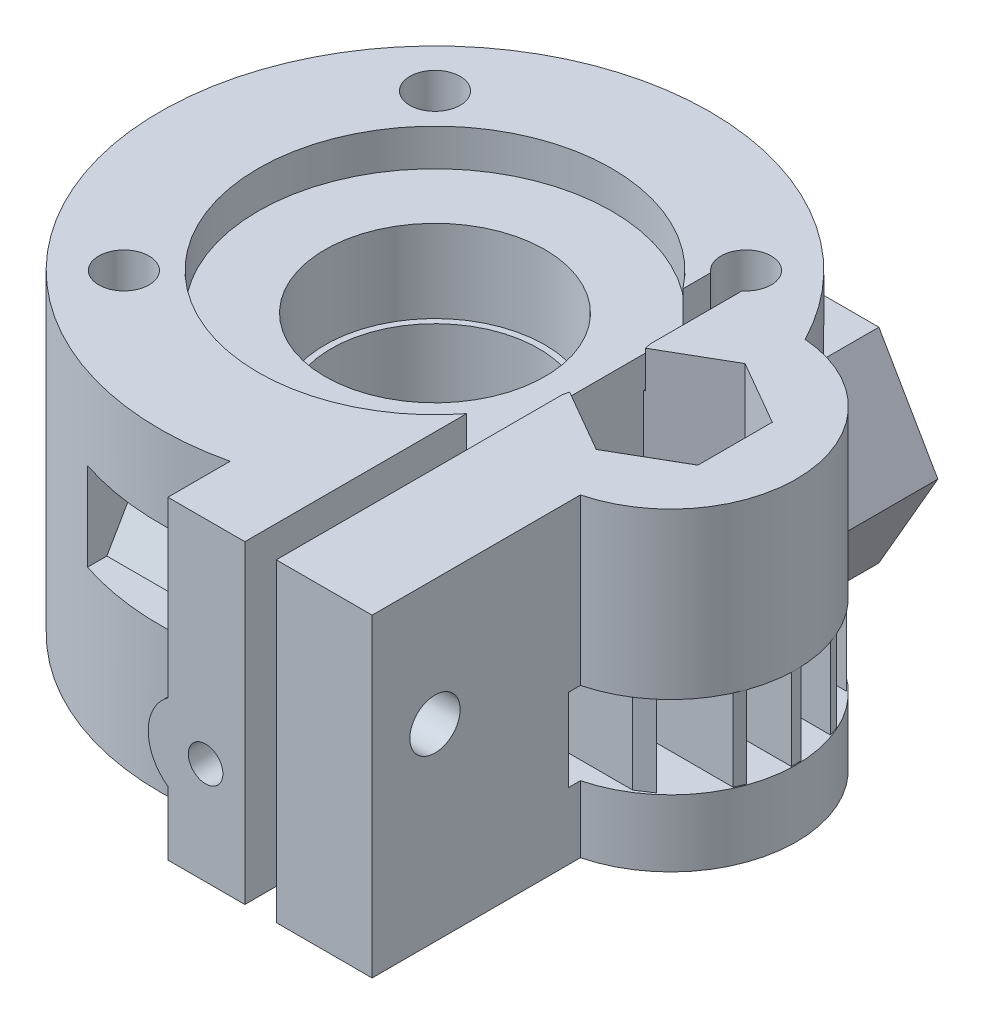
from build123d import *

# Parameters (mm, degrees)
BOSS_EXTRUDE1_DEPTH     = 20
CUT_EXTRUDE1_REACH      = 22
SKETCH2_R               = 6.6
SKETCH2_R_2             = 1.6
SKETCH2_R_3             = 2.6
SKETCH3_R               = 11.25
CUT_EXTRUDE2_DEPTH      = 2.35
SKETCH4_R               = 7
CUT_EXTRUDE3_DEPTH      = 5.25
CUT_EXTRUDE4_DEPTH      = 6
CUT_EXTRUDE5_DEPTH      = 5.25
BOSS_EXTRUDE2_REACH     = 40.5
SKETCH10_R              = 3
BOSS_EXTRUDE3_REACH     = 41
SKETCH8_R               = 1.1
CUT_EXTRUDE6_DEPTH      = 40
SKETCH14_R              = 2.25
CUT_EXTRUDE7_DEPTH      = 5
SKETCH15_R              = 1.6
CUT_EXTRUDE8_DEPTH      = 13
CUT_EXTRUDE9_DEPTH      = 9.5
CUT_EXTRUDE9_DEPTH_BACK = 1.5
BOSS_EXTRUDE4_REACH     = 17.75
SKETCH17_W              = 1.481378883
SKETCH17_H              = 0.6
SKETCH17_W_2            = 5.287146776
SKETCH17_W_3            = 2.276797121


with BuildPart() as part:
    # Sketch1 → Boss-Extrude1 (new body)
    with BuildSketch(Plane(origin=(0, 0, 0), x_dir=(1, 0, 0), z_dir=(0, 1, 0))):
        with BuildLine():
            Line((4, -21), (17, -21))
            Line((17, -21), (17, -7.745966692))
            ThreePointArc((17, -7.745966692), (22.967354114, 0.721989217), (15.575, 7.979309181))
            ThreePointArc((15.575, 7.979309181), (-15.882243174, 7.348765322), (4, -17.036725037))
            Line((4, -17.036725037), (4, -21))
        make_face()
    extrude(amount=BOSS_EXTRUDE1_DEPTH)

    # Sketch2 → Cut-Extrude1 (cut, up to next)
    with BuildSketch(Plane(origin=(0, 20, 0), x_dir=(1, 0, 0), z_dir=(0, 1, 0)), mode=Mode.PRIVATE) as cut_extrude1_sk1:
        Circle(SKETCH2_R)
    cut_extrude1_tool1 = extrude(cut_extrude1_sk1.sketch, amount=-CUT_EXTRUDE1_REACH, mode=Mode.PRIVATE) & part.part
    add(cut_extrude1_tool1.solids().sort_by_distance((0, 20, 0))[0], mode=Mode.SUBTRACT)
    # Sketch2 → Cut-Extrude1 (cut, up to next)
    with BuildSketch(Plane(origin=(0, 20, 0), x_dir=(1, 0, 0), z_dir=(0, 1, 0)), mode=Mode.PRIVATE) as cut_extrude1_sk2:
        with Locations((-9.899494937, 9.899494937)):
            Circle(SKETCH2_R_2)
    cut_extrude1_tool2 = extrude(cut_extrude1_sk2.sketch, amount=-CUT_EXTRUDE1_REACH, mode=Mode.PRIVATE) & part.part
    add(cut_extrude1_tool2.solids().sort_by_distance((-9.899495, 20, -9.899495))[0], mode=Mode.SUBTRACT)
    # Sketch2 → Cut-Extrude1 (cut, up to next)
    with BuildSketch(Plane(origin=(0, 20, 0), x_dir=(1, 0, 0), z_dir=(0, 1, 0)), mode=Mode.PRIVATE) as cut_extrude1_sk3:
        with Locations((-9.899494937, -9.899494937)):
            Circle(SKETCH2_R_2)
    cut_extrude1_tool3 = extrude(cut_extrude1_sk3.sketch, amount=-CUT_EXTRUDE1_REACH, mode=Mode.PRIVATE) & part.part
    add(cut_extrude1_tool3.solids().sort_by_distance((-9.899495, 20, 9.899495))[0], mode=Mode.SUBTRACT)
    # Sketch2 → Cut-Extrude1 (cut, up to next)
    with BuildSketch(Plane(origin=(0, 20, 0), x_dir=(1, 0, 0), z_dir=(0, 1, 0)), mode=Mode.PRIVATE) as cut_extrude1_sk4:
        with Locations((15, 0)):
            Circle(SKETCH2_R_3)
    cut_extrude1_tool4 = extrude(cut_extrude1_sk4.sketch, amount=-CUT_EXTRUDE1_REACH, mode=Mode.PRIVATE) & part.part
    add(cut_extrude1_tool4.solids().sort_by_distance((15, 20, 0))[0], mode=Mode.SUBTRACT)
    # Sketch2 → Cut-Extrude1 (cut, up to next)
    with BuildSketch(Plane(origin=(0, 20, 0), x_dir=(1, 0, 0), z_dir=(0, 1, 0)), mode=Mode.PRIVATE) as cut_extrude1_sk5:
        with BuildLine():
            Line((8.899494937, -21), (8.899494937, 8.650495337))
            ThreePointArc((8.899494937, 8.650495337), (9.899494937, 11.499494937), (10.899494937, 8.650495337))
            Line((10.899494937, 8.650495337), (10.899494937, -21))
            Line((10.899494937, -21), (8.899494937, -21))
        make_face()
    cut_extrude1_tool5 = extrude(cut_extrude1_sk5.sketch, amount=-CUT_EXTRUDE1_REACH, mode=Mode.PRIVATE) & part.part
    add(cut_extrude1_tool5.solids().sort_by_distance((9.899495, 20, 4.346591))[0], mode=Mode.SUBTRACT)

    # Sketch3 → Cut-Extrude2 (cut)
    with BuildSketch(Plane(origin=(0, 20, 0), x_dir=(1, 0, 0), z_dir=(0, 1, 0))):
        Circle(SKETCH3_R)
    extrude(amount=-CUT_EXTRUDE2_DEPTH, mode=Mode.SUBTRACT)

    # Sketch4 → Cut-Extrude3 (cut)
    with BuildSketch(Plane(origin=(0, 17.65, 0), x_dir=(1, 0, 0), z_dir=(0, 1, 0))):
        Circle(SKETCH4_R)
    extrude(amount=-CUT_EXTRUDE3_DEPTH, mode=Mode.SUBTRACT)

    # Sketch5 → Cut-Extrude4 (cut)
    with BuildSketch(Plane(origin=(0, 20, 0), x_dir=(1, 0, 0), z_dir=(0, 1, 0))):
        Polygon((19.100505063, 2.367427702), (15, 4.734855404), (10.899494937, 2.367427702), (10.899494937, -2.367427702), (15, -4.734855404), (19.100505063, -2.367427702), align=None)
    extrude(amount=-CUT_EXTRUDE4_DEPTH, mode=Mode.SUBTRACT)

    # Sketch6 → Cut-Extrude5 (cut)
    with BuildSketch(Plane(origin=(0, 4.25, 0), x_dir=(1, 0, 0), z_dir=(0, 1, 0))):
        with BuildLine():
            Line((15, 8.5), (23.5, 8.5))
            Line((23.5, 8.5), (23.5, 0))
            Line((23.5, 0), (23.5, -8.5))
            Line((23.5, -8.5), (15, -8.5))
            ThreePointArc((15, -8.5), (10.626786079, -7.288689869), (7.5, -4))
            Line((7.5, -4), (5, -4))
            Line((5, -4), (5, 0))
            Line((5, 0), (5, 4))
            Line((5, 4), (7.5, 4))
            ThreePointArc((7.5, 4), (10.626786079, 7.288689869), (15, 8.5))
        make_face()
    extrude(amount=CUT_EXTRUDE5_DEPTH, mode=Mode.SUBTRACT)

    # Sketch10 → Boss-Extrude2 (add, up to next)
    with BuildSketch(Plane.XY.offset(21), mode=Mode.PRIVATE) as boss_extrude2_sk1:
        with Locations((5.75, 6.5)):
            Circle(SKETCH10_R)
    boss_extrude2_tool1 = extrude(boss_extrude2_sk1.sketch, amount=-BOSS_EXTRUDE2_REACH, mode=Mode.PRIVATE) - part.part
    add(boss_extrude2_tool1.solids().sort_by_distance((5.75, 6.5, 21))[0])

    # Sketch11 → Boss-Extrude3 (add, up to next)
    with BuildSketch(Plane.XY.offset(-18), mode=Mode.PRIVATE) as boss_extrude3_sk1:
        Polygon((-1.005553499, 6.5), (2.74722325, 0), (10.25277675, 0), (14.005553499, 6.5), (10.25277675, 13), (2.74722325, 13), align=None)
    boss_extrude3_tool1 = extrude(boss_extrude3_sk1.sketch, amount=BOSS_EXTRUDE3_REACH, mode=Mode.PRIVATE) - part.part
    add(boss_extrude3_tool1.solids().sort_by_distance((6.5, 6.5, -18))[0])

    # Sketch8 → Cut-Extrude6 (cut, through all)
    with BuildSketch(Plane.XY.offset(21)):
        with Locations((6.399494937, 6.5)):
            Circle(SKETCH8_R)
    extrude(amount=-CUT_EXTRUDE6_DEPTH, mode=Mode.SUBTRACT)

    # Sketch13 → Cut-Revolve1 (revolve, cut)
    with BuildSketch(Plane.ZY.offset(-6.5)):
        Polygon((-6, 6.5), (-4, 6.5), (-4, 8.678199262), (-6, 7), align=None)
    revolve(axis=Axis((6.5, 6.5, -18), (0, 0, 1)), mode=Mode.SUBTRACT)

    # Sketch14 → Cut-Extrude7 (cut)
    with BuildSketch(Plane(origin=(0, 0, -18), x_dir=(-1, 0, 0), z_dir=(0, 0, -1))):
        with Locations((-6.399494937, 6.5)):
            Circle(SKETCH14_R)
    extrude(amount=-CUT_EXTRUDE7_DEPTH, mode=Mode.SUBTRACT)

    # Sketch15 → Cut-Extrude8 (cut)
    with BuildSketch(Plane(origin=(17, 0, 0), x_dir=(0, 0, -1), z_dir=(1, 0, 0))):
        with Locations((-17, 12)):
            Circle(SKETCH15_R)
    extrude(amount=-CUT_EXTRUDE8_DEPTH, mode=Mode.SUBTRACT)

    # Sketch16 → Cut-Extrude9 (cut, two sides)
    with BuildSketch(Plane.ZY.offset(-4)) as cut_extrude9_sk:
        Polygon((20.233161507, 12), (18.616580754, 14.8), (15.383419246, 14.8), (13.766838493, 12), (15.383419246, 9.2), (18.616580754, 9.2), align=None)
    extrude(amount=CUT_EXTRUDE9_DEPTH, mode=Mode.SUBTRACT)
    extrude(cut_extrude9_sk.sketch, amount=-CUT_EXTRUDE9_DEPTH_BACK, mode=Mode.SUBTRACT)

    # Sketch17 → Boss-Extrude4 (add, up to next)
    with BuildSketch(Plane(origin=(0, 4.25, 0), x_dir=(1, 0, 0), z_dir=(0, 1, 0)), mode=Mode.PRIVATE) as boss_extrude4_sk1:
        with Locations((11.640184379, 0.05)):
            Rectangle(SKETCH17_W, SKETCH17_H)
    boss_extrude4_tool1 = extrude(boss_extrude4_sk1.sketch, amount=BOSS_EXTRUDE4_REACH, mode=Mode.PRIVATE) - part.part
    add(boss_extrude4_tool1.solids().sort_by_distance((11.640184, 4.25, -0.05))[0])
    # Sketch17 → Boss-Extrude4 (add, up to next)
    with BuildSketch(Plane(origin=(0, 4.25, 0), x_dir=(1, 0, 0), z_dir=(0, 1, 0)), mode=Mode.PRIVATE) as boss_extrude4_sk2:
        Polygon((22.23765915, 3.330781542), (10.899494937, 3.330781542), (10.899494937, 2.730781542), (22.440052992, 2.730781542), align=None)
    boss_extrude4_tool2 = extrude(boss_extrude4_sk2.sketch, amount=BOSS_EXTRUDE4_REACH, mode=Mode.PRIVATE) - part.part
    add(boss_extrude4_tool2.solids().sort_by_distance((16.619325, 4.25, -3.029897))[0])
    # Sketch17 → Boss-Extrude4 (add, up to next)
    with BuildSketch(Plane(origin=(0, 4.25, 0), x_dir=(1, 0, 0), z_dir=(0, 1, 0)), mode=Mode.PRIVATE) as boss_extrude4_sk3:
        Polygon((22.477954877, -2.64697567), (10.899494937, -2.64697567), (10.899494937, -3.24697567), (22.217055012, -3.24697567), align=None)
    boss_extrude4_tool3 = extrude(boss_extrude4_sk3.sketch, amount=BOSS_EXTRUDE4_REACH, mode=Mode.PRIVATE) - part.part
    add(boss_extrude4_tool3.solids().sort_by_distance((16.623748, 4.25, 2.945836))[0])
    # Sketch17 → Boss-Extrude4 (add, up to next)
    with BuildSketch(Plane(origin=(0, 4.25, 0), x_dir=(1, 0, 0), z_dir=(0, 1, 0)), mode=Mode.PRIVATE) as boss_extrude4_sk4:
        Polygon((20.100469452, -6), (10.899494937, -6), (10.899494937, -6.6), (19.187050839, -6.6), align=None)
    boss_extrude4_tool4 = extrude(boss_extrude4_sk4.sketch, amount=BOSS_EXTRUDE4_REACH, mode=Mode.PRIVATE) - part.part
    add(boss_extrude4_tool4.solids().sort_by_distance((15.275603, 4.25, 6.294777))[0])
    # Sketch17 → Boss-Extrude4 (add, up to next)
    with BuildSketch(Plane(origin=(0, 4.25, 0), x_dir=(1, 0, 0), z_dir=(0, 1, 0)), mode=Mode.PRIVATE) as boss_extrude4_sk5:
        with Locations((20.290372632, 0.05)):
            Rectangle(SKETCH17_W_2, SKETCH17_H)
    boss_extrude4_tool5 = extrude(boss_extrude4_sk5.sketch, amount=BOSS_EXTRUDE4_REACH, mode=Mode.PRIVATE) - part.part
    add(boss_extrude4_tool5.solids().sort_by_distance((20.290373, 4.25, -0.05))[0])
    # Sketch17 → Boss-Extrude4 (add, up to next)
    with BuildSketch(Plane(origin=(0, 4.25, 0), x_dir=(1, 0, 0), z_dir=(0, 1, 0)), mode=Mode.PRIVATE) as boss_extrude4_sk6:
        Polygon((10.899494937, 6.25), (10.899494937, 5.65), (20.530479048, 5.65), (19.895586914, 6.25), align=None)
    boss_extrude4_tool6 = extrude(boss_extrude4_sk6.sketch, amount=BOSS_EXTRUDE4_REACH, mode=Mode.PRIVATE) - part.part
    add(boss_extrude4_tool6.solids().sort_by_distance((15.558067, 4.25, -5.946592))[0])
    # Sketch17 → Boss-Extrude4 (add, up to next)
    with BuildSketch(Plane(origin=(0, 4.25, 0), x_dir=(1, 0, 0), z_dir=(0, 1, 0)), mode=Mode.PRIVATE) as boss_extrude4_sk7:
        Polygon((8.899494937, -3.24697567), (8.899494937, -2.64697567), (6.922653913, -2.64697567), (6.045950695, -2.64697567), (5.800562103, -3.24697567), (7.144610194, -3.24697567), align=None)
    boss_extrude4_tool7 = extrude(boss_extrude4_sk7.sketch, amount=BOSS_EXTRUDE4_REACH, mode=Mode.PRIVATE) - part.part
    add(boss_extrude4_tool7.solids().sort_by_distance((7.410533, 4.25, 2.951098))[0])
    # Sketch17 → Boss-Extrude4 (add, up to next)
    with BuildSketch(Plane(origin=(0, 4.25, 0), x_dir=(1, 0, 0), z_dir=(0, 1, 0)), mode=Mode.PRIVATE) as boss_extrude4_sk8:
        Polygon((8.899494937, 3.330781542), (7.179776581, 3.330781542), (5.759276556, 3.330781542), (6.078412351, 2.730781542), (6.950600509, 2.730781542), (8.899494937, 2.730781542), align=None)
    boss_extrude4_tool8 = extrude(boss_extrude4_sk8.sketch, amount=BOSS_EXTRUDE4_REACH, mode=Mode.PRIVATE) - part.part
    add(boss_extrude4_tool8.solids().sort_by_distance((7.407746, 4.25, -3.036135))[0])
    # Sketch17 → Boss-Extrude4 (add, up to next)
    with BuildSketch(Plane(origin=(0, 4.25, 0), x_dir=(1, 0, 0), z_dir=(0, 1, 0)), mode=Mode.PRIVATE) as boss_extrude4_sk9:
        with Locations((7.761096377, 0.05)):
            Rectangle(SKETCH17_W_3, SKETCH17_H)
    boss_extrude4_tool9 = extrude(boss_extrude4_sk9.sketch, amount=BOSS_EXTRUDE4_REACH, mode=Mode.PRIVATE) - part.part
    add(boss_extrude4_tool9.solids().sort_by_distance((7.761096, 4.25, -0.05))[0])


solid = part.part
